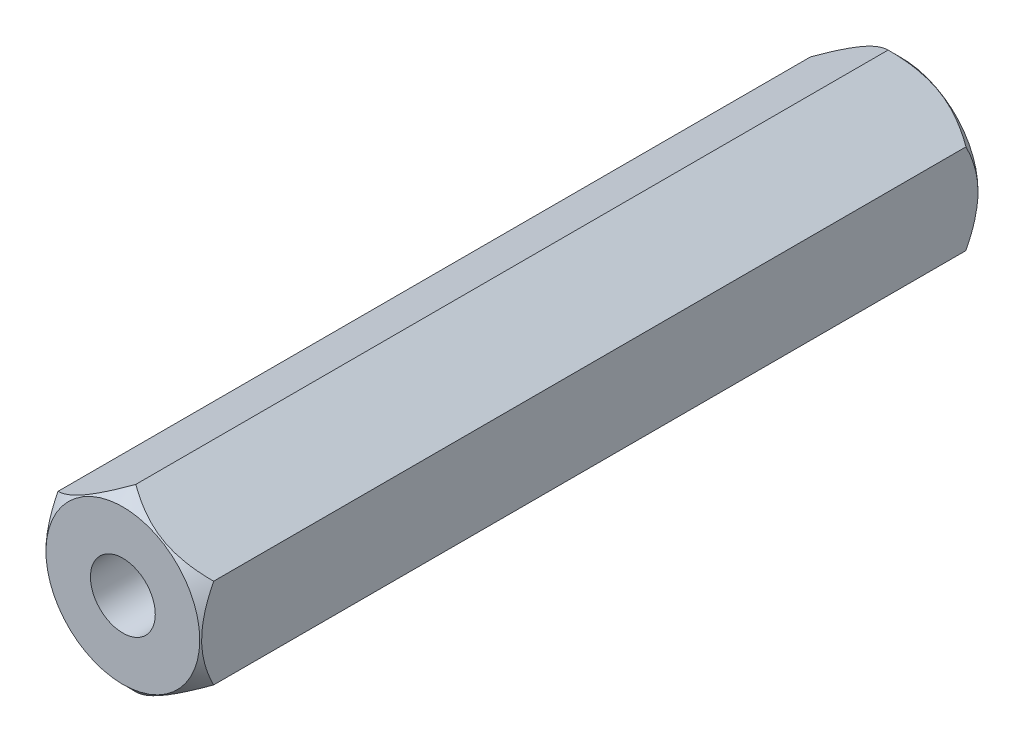
from build123d import *

# Parameters (mm, degrees)
SALIENTE_EXTRUIR1_DEPTH = 15
CROQUIS3_R              = 1.25
CORTAR_EXTRUIR1_DEPTH   = 30


with BuildPart() as part:
    # Croquis1 → Saliente-Extruir1 (new body, symmetric)
    with BuildSketch(Plane.XY):
        Polygon((0, 3.464101615), (-3, 1.732050808), (-3, -1.732050808), (0, -3.464101615), (3, -1.732050808), (3, 1.732050808), align=None)
    extrude(amount=SALIENTE_EXTRUIR1_DEPTH, both=True)

    # Croquis2 → Cortar-Revolución2 (revolve, cut)
    with BuildSketch(Plane(origin=(0, 0, 0), x_dir=(0, 0, -1), z_dir=(1, 0, 0))):
        Polygon((15, 2.964101615), (19.5, 2.964101615), (19.5, 7.964101615), (14.5, 7.964101615), (14.5, 3.464101615), align=None)
        Polygon((-19.5, 2.964101615), (-19.5, 7.964101615), (-14.5, 7.964101615), (-14.5, 3.464101615), (-15, 2.964101615), align=None)
    revolve(axis=Axis((0, 0, 17.803147854), (0, 0, -1)), mode=Mode.SUBTRACT)

    # Croquis3 → Cortar-Extruir1 (cut)
    with BuildSketch(Plane.XY.offset(15)):
        Circle(CROQUIS3_R)
    extrude(amount=-CORTAR_EXTRUIR1_DEPTH, mode=Mode.SUBTRACT)


solid = part.part
